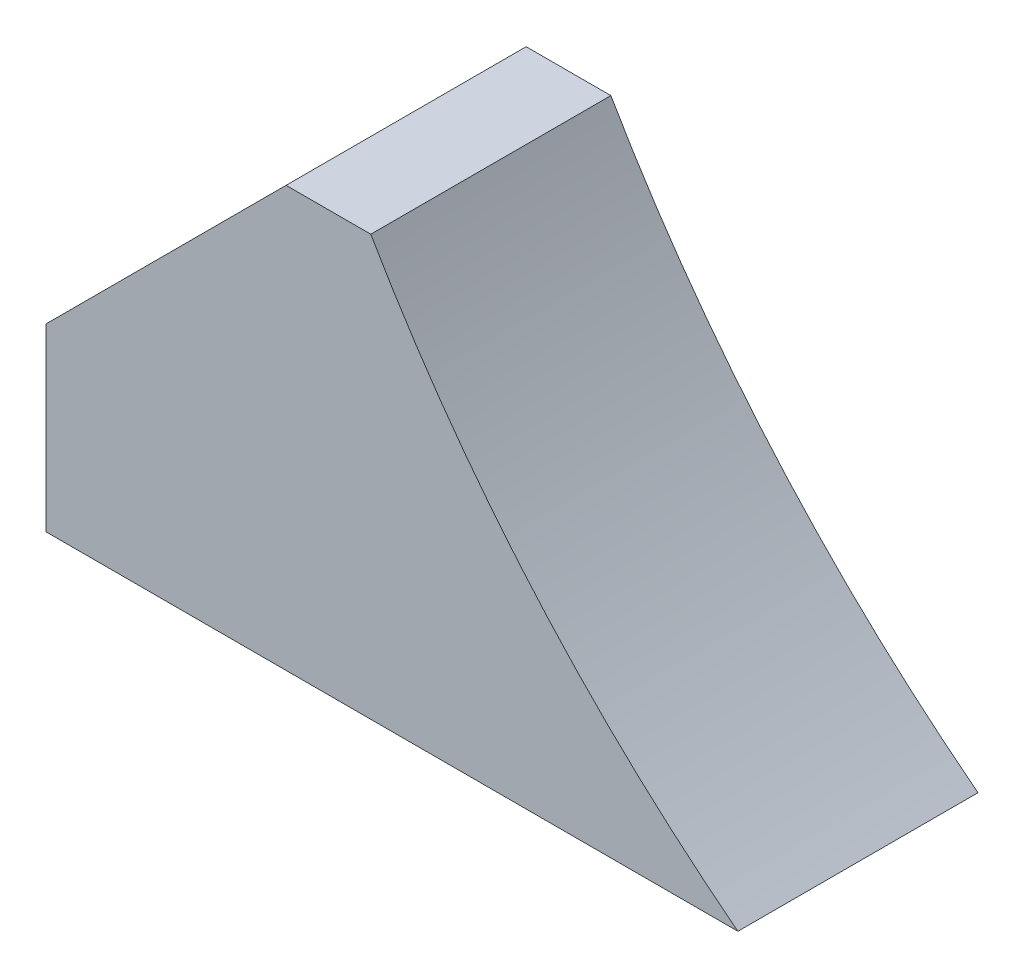
from build123d import *

# Parameters (mm, degrees)
BOSS_EXTRUDE1_DEPTH = 25.4
CHAMFER1_SIZE       = 25.4


with BuildPart() as part:
    # Sketch2 → Boss-Extrude1 (new body)
    with BuildSketch(Plane.XY):
        with BuildLine():
            Line((-28.394744795, 6.35), (-101.6, 6.35))
            Line((-101.6, 6.35), (-101.6, 50.8))
            Line((-101.6, 50.8), (-67.239627541, 50.8))
            ThreePointArc((-67.239627541, 50.8), (-49.99007984, 26.676106864), (-28.394744795, 6.35))
        make_face()
    extrude(amount=-BOSS_EXTRUDE1_DEPTH)

    # Chamfer1
    chamfer1_edges = [part.edges().sort_by_distance(p)[0] for p in [
        (-101.6, 50.8, -12.7),
    ]]
    chamfer(chamfer1_edges, length=CHAMFER1_SIZE)


solid = part.part
